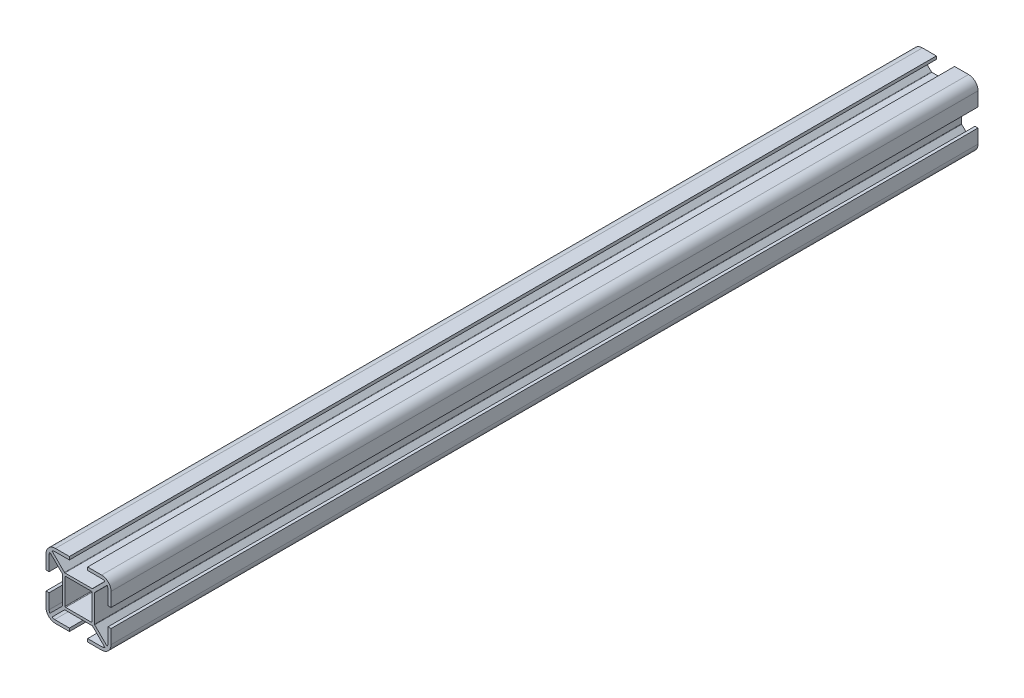
from build123d import *

# Parameters (mm, degrees)
EXTRUDE_1_DEPTH = 400


with BuildPart() as part:
    # Эскиз1 → Бобышка-Вытянуть1 (new body)
    with BuildSketch(Plane.XY):
        with BuildLine():
            ThreePointArc((-10.65, 15), (-13.725914498, 13.725914498), (-15, 10.65))
            Line((-15, 10.65), (-15, 4.2))
            Line((-15, 4.2), (-13.6, 4.2))
            Line((-13.6, 4.2), (-13.6, 11))
            ThreePointArc((-13.6, 11), (-13.457683666, 11.620521732), (-13.186420313, 12.196470819))
            Line((-13.186420313, 12.196470819), (-7.487867966, 6.497918472))
            ThreePointArc((-7.487867966, 6.497918472), (-7.42283614, 6.400591467), (-7.4, 6.285786438))
            Line((-7.4, 6.285786438), (-7.4, 0))
            Line((-7.4, 0), (-7.4, -6.285786438))
            ThreePointArc((-7.4, -6.285786438), (-7.42283614, -6.400591467), (-7.487867966, -6.497918472))
            Line((-7.487867966, -6.497918472), (-13.186420313, -12.196470819))
            ThreePointArc((-13.186420313, -12.196470819), (-13.457683666, -11.620521732), (-13.6, -11))
            Line((-13.6, -11), (-13.6, -4.2))
            Line((-13.6, -4.2), (-15, -4.2))
            Line((-15, -4.2), (-15, -10.65))
            ThreePointArc((-15, -10.65), (-13.725914498, -13.725914498), (-10.65, -15))
            Line((-10.65, -15), (-4.2, -15))
            Line((-4.2, -15), (-4.2, -13.6))
            Line((-4.2, -13.6), (-11, -13.6))
            ThreePointArc((-11, -13.6), (-11.620521732, -13.457683666), (-12.196470819, -13.186420313))
            Line((-12.196470819, -13.186420313), (-6.497918472, -7.487867966))
            ThreePointArc((-6.497918472, -7.487867966), (-6.400591467, -7.42283614), (-6.285786438, -7.4))
            Line((-6.285786438, -7.4), (6.285786438, -7.4))
            ThreePointArc((6.285786438, -7.4), (6.400591467, -7.42283614), (6.497918472, -7.487867966))
            Line((6.497918472, -7.487867966), (12.196470819, -13.186420313))
            ThreePointArc((12.196470819, -13.186420313), (11.620521732, -13.457683666), (11, -13.6))
            Line((11, -13.6), (4.2, -13.6))
            Line((4.2, -13.6), (4.2, -15))
            Line((4.2, -15), (10.65, -15))
            ThreePointArc((10.65, -15), (13.725914498, -13.725914498), (15, -10.65))
            Line((15, -10.65), (15, -4.2))
            Line((15, -4.2), (13.6, -4.2))
            Line((13.6, -4.2), (13.6, -11))
            ThreePointArc((13.6, -11), (13.457683666, -11.620521732), (13.186420313, -12.196470819))
            Line((13.186420313, -12.196470819), (7.487867966, -6.497918472))
            ThreePointArc((7.487867966, -6.497918472), (7.42283614, -6.400591467), (7.4, -6.285786438))
            Line((7.4, -6.285786438), (7.4, 0))
            Line((7.4, 0), (7.4, 6.285786438))
            ThreePointArc((7.4, 6.285786438), (7.42283614, 6.400591467), (7.487867966, 6.497918472))
            Line((7.487867966, 6.497918472), (13.186420313, 12.196470819))
            ThreePointArc((13.186420313, 12.196470819), (13.457683666, 11.620521732), (13.6, 11))
            Line((13.6, 11), (13.6, 4.2))
            Line((13.6, 4.2), (15, 4.2))
            Line((15, 4.2), (15, 10.65))
            ThreePointArc((15, 10.65), (13.725914498, 13.725914498), (10.65, 15))
            Line((10.65, 15), (4.2, 15))
            Line((4.2, 15), (4.2, 13.6))
            Line((4.2, 13.6), (11, 13.6))
            ThreePointArc((11, 13.6), (11.620521732, 13.457683666), (12.196470819, 13.186420313))
            Line((12.196470819, 13.186420313), (6.497918472, 7.487867966))
            ThreePointArc((6.497918472, 7.487867966), (6.400591467, 7.42283614), (6.285786438, 7.4))
            Line((6.285786438, 7.4), (0, 7.4))
            Line((0, 7.4), (-6.285786438, 7.4))
            ThreePointArc((-6.285786438, 7.4), (-6.400591467, 7.42283614), (-6.497918472, 7.487867966))
            Line((-6.497918472, 7.487867966), (-12.196470819, 13.186420313))
            ThreePointArc((-12.196470819, 13.186420313), (-11.620521732, 13.457683666), (-11, 13.6))
            Line((-11, 13.6), (-4.2, 13.6))
            Line((-4.2, 13.6), (-4.2, 15))
            Line((-4.2, 15), (-10.65, 15))
        make_face()
        with BuildLine():
            Line((0.01702519, 6.2), (5.9, 6.2))
            ThreePointArc((5.9, 6.2), (6.112132034, 6.112132034), (6.2, 5.9))
            Line((6.2, 5.9), (6.2, -0.01702519))
            Line((6.2, -0.01702519), (6.2, -5.9))
            ThreePointArc((6.2, -5.9), (6.112132034, -6.112132034), (5.9, -6.2))
            Line((5.9, -6.2), (0.01702519, -6.2))
            Line((0.01702519, -6.2), (-0.01702519, -6.2))
            Line((-0.01702519, -6.2), (-5.9, -6.2))
            ThreePointArc((-5.9, -6.2), (-6.112132034, -6.112132034), (-6.2, -5.9))
            Line((-6.2, -5.9), (-6.2, -0.01702519))
            Line((-6.2, -0.01702519), (-6.2, 0))
            Line((-6.2, 0), (-6.2, 5.9))
            ThreePointArc((-6.2, 5.9), (-6.112132034, 6.112132034), (-5.9, 6.2))
            Line((-5.9, 6.2), (0, 6.2))
            Line((0, 6.2), (0.01702519, 6.2))
        make_face(mode=Mode.SUBTRACT)
    extrude(amount=EXTRUDE_1_DEPTH)


solid = part.part
